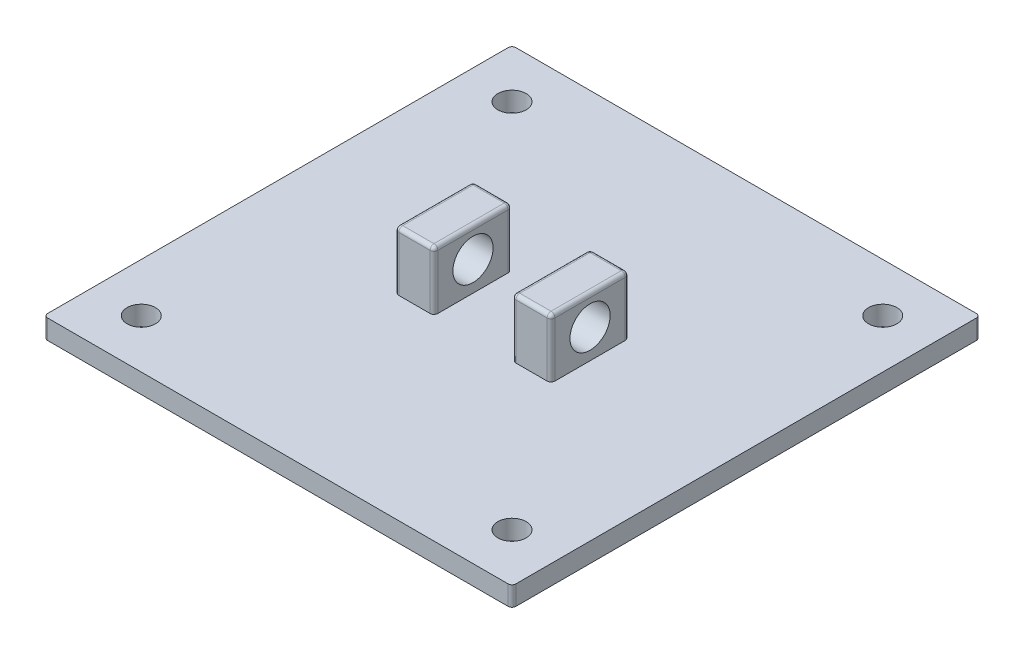
from build123d import *

# Parameters (mm, degrees)
ESQUISSE1_W             = 240
ESQUISSE1_H             = 240
BOSS_EXTRU_1_DEPTH      = 10
ESQUISSE2_R             = 7.25
ENL_V_MAT_EXTRU_1_DEPTH = 10
ESQUISSE5_W             = 20
ESQUISSE5_H             = 40
BOSS_EXTRU_5_DEPTH      = 30
ESQUISSE7_R             = 10.3
ENL_V_MAT_EXTRU_2_DEPTH = 80
CONG_1_R                = 2
CONG_2_R                = 2
CONG_3_R                = 2
CONG_4_R                = 2
CONG_5_R                = 2
CONG_6_R                = 2
CONG_7_R                = 2
CONG_8_R                = 2
CONG_9_R                = 2
CONG_10_R               = 2
CONG_11_R               = 2
CONG_12_R               = 2


with BuildPart() as part:
    # Esquisse1 → Boss.-Extru.1 (new body)
    with BuildSketch(Plane(origin=(0, 0, 0), x_dir=(1, 0, 0), z_dir=(0, 1, 0))):
        Rectangle(ESQUISSE1_W, ESQUISSE1_H)
    extrude(amount=BOSS_EXTRU_1_DEPTH)

    # Esquisse2 → Enlèv. mat.-Extru.1 (cut)
    with BuildSketch(Plane(origin=(0, 10, 0), x_dir=(1, 0, 0), z_dir=(0, 1, 0))):
        with Locations((-95, -95)):
            Circle(ESQUISSE2_R)
        with Locations((-95, 95)):
            Circle(ESQUISSE2_R)
        with Locations((95, 95)):
            Circle(ESQUISSE2_R)
        with Locations((95, -95)):
            Circle(ESQUISSE2_R)
    extrude(amount=-ENL_V_MAT_EXTRU_1_DEPTH, mode=Mode.SUBTRACT)

    # Esquisse5 → Boss.-Extru.5 (add)
    with BuildSketch(Plane(origin=(0, 10, 0), x_dir=(1, 0, 0), z_dir=(0, 1, 0))):
        with Locations((-30, 0)):
            Rectangle(ESQUISSE5_W, ESQUISSE5_H)
        with Locations((30, 0)):
            Rectangle(ESQUISSE5_W, ESQUISSE5_H)
    extrude(amount=BOSS_EXTRU_5_DEPTH)

    # Esquisse7 → Enlèv. mat.-Extru.2 (cut)
    with BuildSketch(Plane.ZY.offset(40)):
        with Locations((0, 25)):
            Circle(ESQUISSE7_R)
    extrude(amount=-ENL_V_MAT_EXTRU_2_DEPTH, mode=Mode.SUBTRACT)

    # Congé1
    cong_1_edges = [part.edges().sort_by_distance(p)[0] for p in [
        (-120, 5, -120),
    ]]
    fillet(cong_1_edges, radius=CONG_1_R)

    # Congé2
    cong_2_edges = [part.edges().sort_by_distance(p)[0] for p in [
        (-120, 5, 120),
    ]]
    fillet(cong_2_edges, radius=CONG_2_R)

    # Congé3
    cong_3_edges = [part.edges().sort_by_distance(p)[0] for p in [
        (120, 5, 120),
    ]]
    fillet(cong_3_edges, radius=CONG_3_R)

    # Congé4
    cong_4_edges = [part.edges().sort_by_distance(p)[0] for p in [
        (120, 5, -120),
    ]]
    fillet(cong_4_edges, radius=CONG_4_R)

    # Congé5
    cong_5_edges = [part.edges().sort_by_distance(p)[0] for p in [
        (30, 40, -20),
    ]]
    fillet(cong_5_edges, radius=CONG_5_R)

    # Congé6
    cong_6_edges = [part.edges().sort_by_distance(p)[0] for p in [
        (30, 40, 20),
    ]]
    fillet(cong_6_edges, radius=CONG_6_R)

    # Congé7
    cong_7_edges = [part.edges().sort_by_distance(p)[0] for p in [
        (40, 24, -20),
        (40, 39.414213562, -19.414213562),
        (40, 40, 0),
        (40, 24, 20),
        (40, 39.414213562, 19.414213562),
    ]]
    fillet(cong_7_edges, radius=CONG_7_R)

    # Congé8
    cong_8_edges = [part.edges().sort_by_distance(p)[0] for p in [
        (-20, 40, 0),
    ]]
    fillet(cong_8_edges, radius=CONG_8_R)

    # Congé9
    cong_9_edges = [part.edges().sort_by_distance(p)[0] for p in [
        (-20, 24, 20),
        (-20.585786438, 39.414213562, 20),
        (-31, 40, 20),
    ]]
    fillet(cong_9_edges, radius=CONG_9_R)

    # Congé10
    cong_10_edges = [part.edges().sort_by_distance(p)[0] for p in [
        (-40, 24, 20),
        (-40, 39.414213562, 19.414213562),
        (-40, 40, -1),
    ]]
    fillet(cong_10_edges, radius=CONG_10_R)

    # Congé11
    cong_11_edges = [part.edges().sort_by_distance(p)[0] for p in [
        (-30, 40, -20),
        (-20, 24, -20),
        (-20.585786438, 39.414213562, -20),
        (-40, 24, -20),
        (-39.414213562, 39.414213562, -20),
    ]]
    fillet(cong_11_edges, radius=CONG_11_R)

    # Congé12
    cong_12_edges = [part.edges().sort_by_distance(p)[0] for p in [
        (20, 40, 0),
        (20, 24, -20),
        (20, 39.414213562, -19.414213562),
        (20, 24, 20),
        (20, 39.414213562, 19.414213562),
    ]]
    fillet(cong_12_edges, radius=CONG_12_R)


solid = part.part
